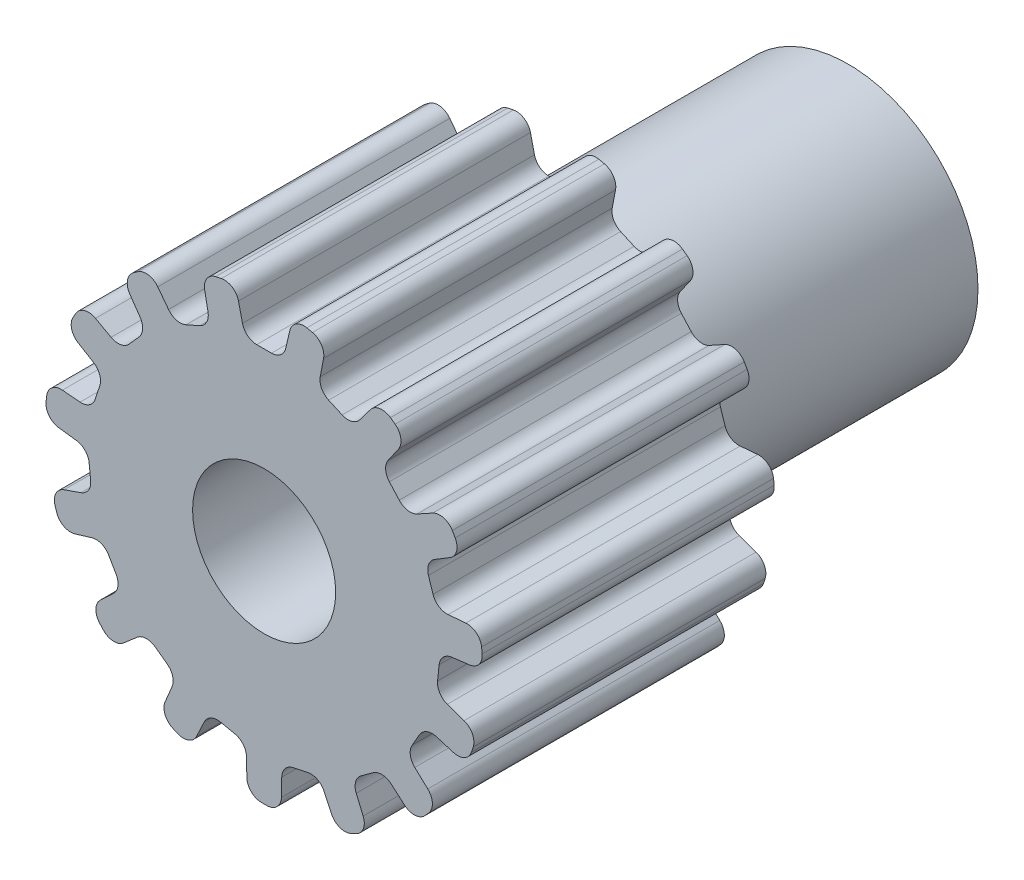
from build123d import *
from build123d.topology import SkipClean

# Parameters (mm, degrees)
SKETCH1_R                = 7.5
SKETCH1_R_2              = 2.45
BOSS_EXTRUDE1_DEPTH      = 10
CUT_EXTRUDE1_DEPTH       = 10
FILLET1_R                = 0.5
CIRPATTERN1_COUNT        = 15
FILLET1_OF_CIRPATTERN1_R = 0.5
BOSS_EXTRUDE2_START      = 10
SKETCH3_R                = 4.45
SKETCH3_R_2              = 2.45
BOSS_EXTRUDE2_DEPTH      = 10


with BuildPart() as part:
    # Sketch1 → Boss-Extrude1 (new body)
    with BuildSketch(Plane.XY):
        Circle(SKETCH1_R)
        Circle(SKETCH1_R_2, mode=Mode.SUBTRACT)
    extrude(amount=BOSS_EXTRUDE1_DEPTH)

    # Sketch2 → Cut-Extrude1 (cut)
    with BuildSketch(Plane(origin=(0, 0, 0), x_dir=(-1, 0, 0), z_dir=(0, 0, -1))):
        Polygon((-0.65, 6), (0.65, 6), (1, 7.5), (-1, 7.5), align=None)
    cut_extrude1 = extrude(amount=-CUT_EXTRUDE1_DEPTH, mode=Mode.SUBTRACT)

    # Fillet1
    fillet1_edges = [part.edges().sort_by_distance(p)[0] for p in [
        (-0.984846702, 7.435057295, 5),
        (-0.65, 6, 5),
        (0.65, 6, 5),
        (0.984846702, 7.435057295, 5),
    ]]
    fillet(fillet1_edges, radius=FILLET1_R)

    # CirPattern1: Cut-Extrude1 ×15 about axis
    cirpattern1_axis = Axis((0, 0, 10), (0, 0, -1))
    for i in range(1, CIRPATTERN1_COUNT):
        add(cut_extrude1.rotate(cirpattern1_axis, i * 360 / CIRPATTERN1_COUNT), mode=Mode.SUBTRACT)

    # Fillet1 of CirPattern1
    fillet1_of_cirpattern1_edges = [part.edges().sort_by_distance(p)[0] for p in [
        (2.124408014, 7.19283606, 5),
        (1.846615311, 5.745651564, 5),
        (3.034224406, 5.216893928, 5),
        (3.923812476, 6.391689577, 5),
        (4.866333285, 5.706908126, 5),
        (4.023934059, 4.497827775, 5),
        (4.893803847, 3.531739502, 5),
        (6.184315427, 4.243140665, 5),
        (6.766825321, 3.234203932, 5),
        (5.505478051, 2.472288702, 5),
        (5.907200144, 1.235915231, 5),
        (7.375494057, 1.360914185, 5),
        (7.497271785, 0.202276495, 5),
        (6.035074873, 0.019268452, 5),
        (5.899187871, -1.273610012, 5),
        (7.29138276, -1.756626722, 5),
        (6.931371847, -2.864626384, 5),
        (5.521152423, -2.437083488, 5),
        (4.871152423, -3.562916512, 5),
        (5.946525145, -4.57043091, 5),
        (5.166974747, -5.436209338, 5),
        (4.05257256, -4.472041552, 5),
        (3.000850467, -5.23616238, 5),
        (3.573459309, -6.593966073, 5),
        (2.509160772, -7.067822311, 5),
        (1.883266085, -5.733743005, 5),
        (0.611674204, -6.004028203, 5),
        (0.582509895, -7.477344597, 5),
        (-0.582509895, -7.477344597, 5),
        (-0.611674204, -6.004028203, 5),
        (-1.883266085, -5.733743005, 5),
        (-2.509160772, -7.067822311, 5),
        (-3.573459309, -6.593966073, 5),
        (-3.000850467, -5.23616238, 5),
        (-4.05257256, -4.472041552, 5),
        (-5.166974747, -5.436209338, 5),
        (-5.946525145, -4.57043091, 5),
        (-4.871152423, -3.562916512, 5),
        (-5.521152423, -2.437083488, 5),
        (-6.931371847, -2.864626384, 5),
        (-7.29138276, -1.756626722, 5),
        (-5.899187871, -1.273610012, 5),
        (-6.035074873, 0.019268452, 5),
        (-7.497271785, 0.202276495, 5),
        (-7.375494057, 1.360914185, 5),
        (-5.907200144, 1.235915231, 5),
        (-5.505478051, 2.472288702, 5),
        (-6.766825321, 3.234203932, 5),
        (-6.184315427, 4.243140665, 5),
        (-4.893803847, 3.531739502, 5),
        (-4.023934059, 4.497827775, 5),
        (-4.866333285, 5.706908126, 5),
        (-3.923812476, 6.391689577, 5),
        (-3.034224406, 5.216893928, 5),
        (-1.846615311, 5.745651564, 5),
        (-2.124408014, 7.19283606, 5),
    ]]
    fillet(fillet1_of_cirpattern1_edges, radius=FILLET1_OF_CIRPATTERN1_R)

    # Sketch3 → Boss-Extrude2 (add)
    with SkipClean():  # the faces are left unmerged after this step: merging them gives an invalid solid
        with BuildSketch(Plane(origin=(0, 0, 0), x_dir=(-1, 0, 0), z_dir=(0, 0, -1)).offset(BOSS_EXTRUDE2_START)):
            Circle(SKETCH3_R)
            Circle(SKETCH3_R_2, mode=Mode.SUBTRACT)
        extrude(amount=-BOSS_EXTRUDE2_DEPTH)


solid = part.part
